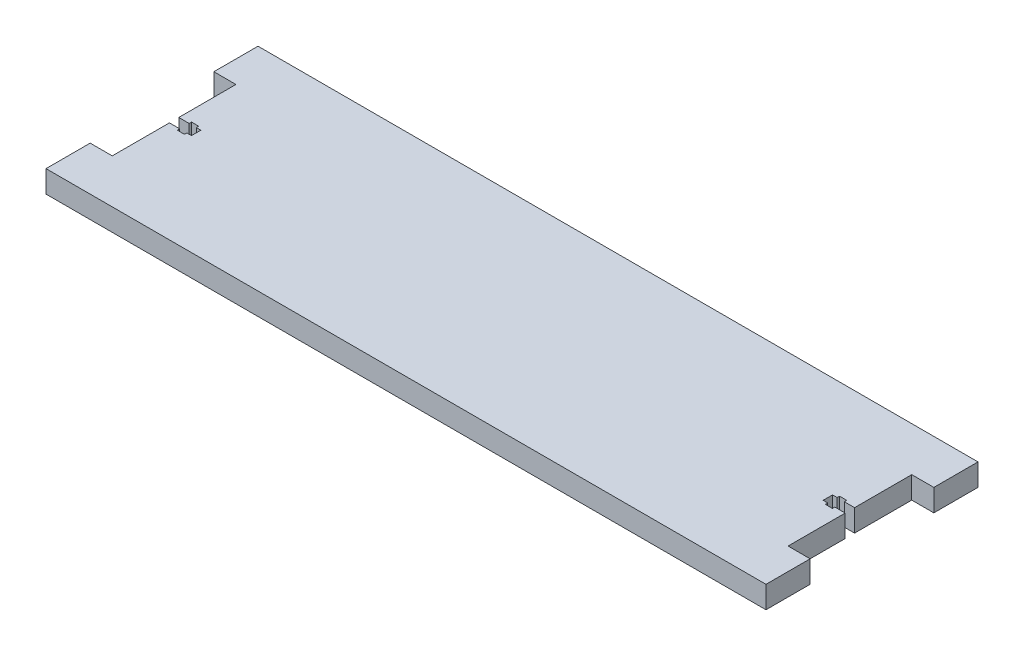
from build123d import *

# Parameters (mm, degrees)
SKETCH1_W           = 388.62
SKETCH1_H           = 121.92
BOSS_EXTRUDE1_DEPTH = 12.7
SKETCH3_W           = 12.7
SKETCH3_H           = 25.4
TABS_DEPTH          = 12.7
SKETCH4_W           = 5.4
SKETCH4_H           = 12.7
SCREW_SLOT_DEPTH    = 12.7
SKETCH5_W           = 4.1
SKETCH5_H           = 8.15
NUT_SLOT_DEPTH      = 12.7


with BuildPart() as part:
    # Sketch1 → Boss-Extrude1 (new body)
    with BuildSketch(Plane(origin=(0, 0, 0), x_dir=(1, 0, 0), z_dir=(0, 1, 0))):
        with Locations((194.31, 60.96)):
            Rectangle(SKETCH1_W, SKETCH1_H)
    extrude(amount=BOSS_EXTRUDE1_DEPTH)

    # Sketch3 → tabs (add)
    with BuildSketch(Plane(origin=(0, 12.7, 0), x_dir=(1, 0, 0), z_dir=(0, 1, 0))):
        with Locations((-6.35, 109.22)):
            Rectangle(SKETCH3_W, SKETCH3_H)
        with Locations((-6.35, 12.7)):
            Rectangle(SKETCH3_W, SKETCH3_H)
        with Locations((394.97, 12.7)):
            Rectangle(SKETCH3_W, SKETCH3_H)
        with Locations((394.97, 109.22)):
            Rectangle(SKETCH3_W, SKETCH3_H)
    extrude(amount=-TABS_DEPTH)

    # Sketch4 → screw slot (cut)
    with BuildSketch(Plane.ZY):
        with Locations((-60.96, 6.35)):
            Rectangle(SKETCH4_W, SKETCH4_H)
    screw_slot = extrude(amount=-SCREW_SLOT_DEPTH, mode=Mode.SUBTRACT)

    # Sketch5 → nut slot (cut)
    with BuildSketch(Plane(origin=(0, 12.7, 0), x_dir=(1, 0, 0), z_dir=(0, 1, 0))):
        with Locations((8, 60.96)):
            Rectangle(SKETCH5_W, SKETCH5_H)
    nut_slot = extrude(amount=-NUT_SLOT_DEPTH, mode=Mode.SUBTRACT)

    # Mirror1: screw slot, nut slot across plane
    add(screw_slot.mirror(Plane(origin=(194.31, 0, 0), x_dir=(0, 0, 1), z_dir=(1, 0, 0))), mode=Mode.SUBTRACT)
    add(nut_slot.mirror(Plane(origin=(194.31, 0, 0), x_dir=(0, 0, 1), z_dir=(1, 0, 0))), mode=Mode.SUBTRACT)


solid = part.part
